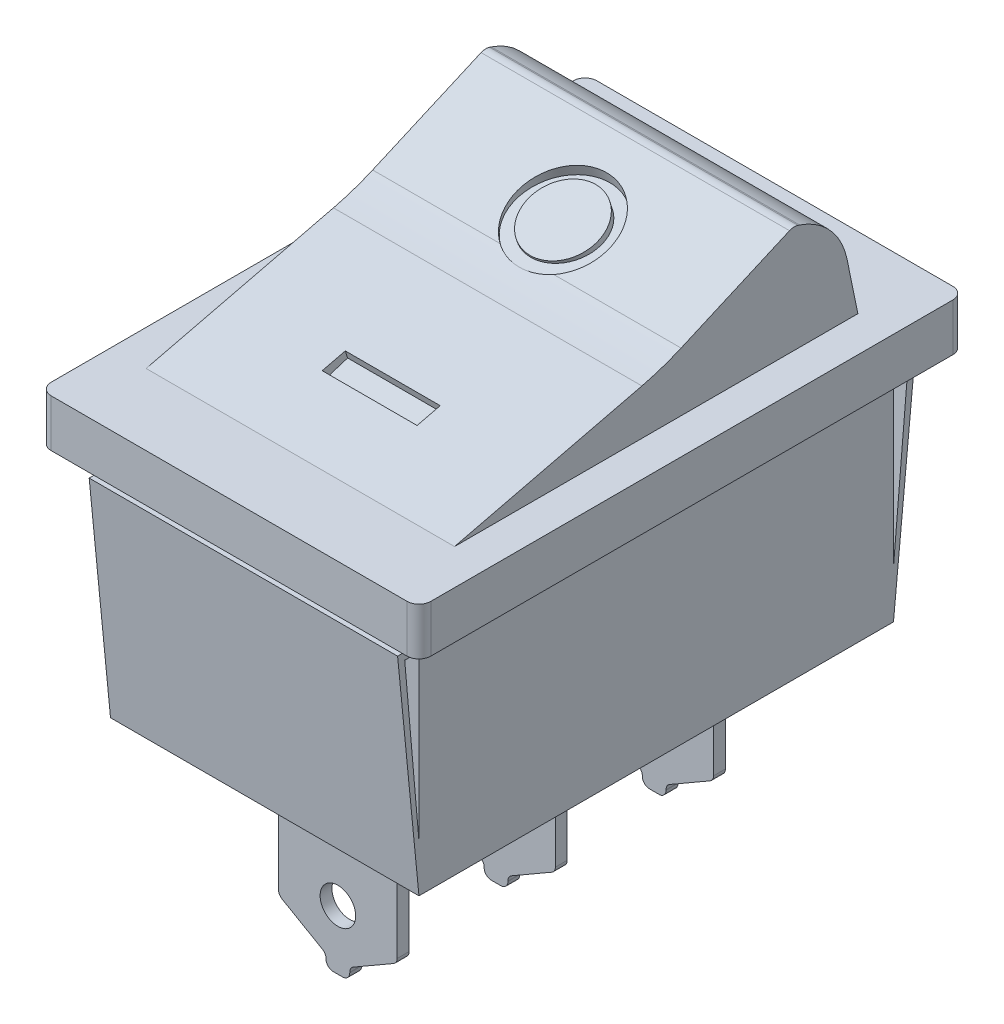
from build123d import *

# Parameters (mm, degrees)
CROQUIS1_W              = 16
CROQUIS1_H              = 23
SALIENTE_EXTRUIR1_DEPTH = 2
CROQUIS2_W              = 13
CROQUIS2_H              = 20
SALIENTE_EXTRUIR2_DEPTH = 10
SALIENTE_EXTRUIR3_DEPTH = 6.5
CROQUIS4_R              = 2
CROQUIS4_R_2            = 1.5
CROQUIS4_W              = 4
CROQUIS4_H              = 1
CORTAR_EXTRUIR1_DEPTH   = 0.6
SALIENTE_EXTRUIR6_DEPTH = 6.5
REDONDEO1_R             = 0.5
CROQUIS6_R              = 0.75
SALIENTE_EXTRUIR7_DEPTH = 0.25
MATRIZL1_COUNT          = 2
MATRIZL1_PITCH          = 6.666666667
MATRIZL2_COUNT          = 2
MATRIZL2_PITCH          = 6.666666667


with BuildPart() as part:
    # Croquis1 → Saliente-Extruir1 (new body)
    with BuildSketch(Plane(origin=(0, 0, 0), x_dir=(1, 0, 0), z_dir=(0, 1, 0))):
        Rectangle(CROQUIS1_W, CROQUIS1_H)
    extrude(amount=SALIENTE_EXTRUIR1_DEPTH)

    # Croquis2 → Saliente-Extruir2 (add)
    with BuildSketch(Plane.XZ):
        Rectangle(CROQUIS2_W, CROQUIS2_H)
    extrude(amount=SALIENTE_EXTRUIR2_DEPTH)

    # Croquis3 → Saliente-Extruir3 (add, symmetric)
    with BuildSketch(Plane(origin=(0, 0, 0), x_dir=(0, 0, -1), z_dir=(1, 0, 0))):
        with BuildLine():
            Line((8.5, 2), (-8.5, 2))
            Line((-8.5, 2), (-0.603629693, 3.914367561))
            ThreePointArc((-0.603629693, 3.914367561), (0.234425411, 4.156697965), (1.048170976, 4.471147542))
            Line((1.048170976, 4.471147542), (5.618369194, 6.470445319))
            ThreePointArc((5.618369194, 6.470445319), (5.795753126, 6.511830798), (5.976190969, 6.486930957))
            Line((5.976190969, 6.486930957), (6.048439126, 6.462964543))
            ThreePointArc((6.048439126, 6.462964543), (7.345603515, 5.609203874), (8.042100494, 4.221243251))
            Line((8.042100494, 4.221243251), (8.5, 2))
        make_face()
    extrude(amount=SALIENTE_EXTRUIR3_DEPTH, both=True)

    # Croquis4 → Cortar-Extruir1 (cut)
    with BuildSketch(Plane(origin=(0, 4.265025315, 1.351360717), x_dir=(1, 0, 0), z_dir=(0, 0.95329272, 0.302047992))):
        with Locations((0, 4)):
            Circle(CROQUIS4_R)
        with Locations((0, 4)):
            Circle(CROQUIS4_R_2, mode=Mode.SUBTRACT)
        with Locations((0, -4)):
            Rectangle(CROQUIS4_W, CROQUIS4_H)
    extrude(amount=-CORTAR_EXTRUIR1_DEPTH, mode=Mode.SUBTRACT)

    # Croquis5 → Saliente-Extruir6 (add, symmetric)
    with BuildSketch(Plane(origin=(0, 0, 0), x_dir=(0, 0, -1), z_dir=(1, 0, 0))):
        Polygon((-10, -0.2), (-10.3, -0.2), (-10.3, -0.5), (-10.6, -0.5), (-10.6, -0.8), (-10.9, -0.8), (-10, -10), (-10, -8), (-10.6, -1.1), (-10.3, -1.1), (-10.3, -0.8), (-10, -0.8), align=None)
    saliente_extruir6 = extrude(amount=SALIENTE_EXTRUIR6_DEPTH, both=True)

    # Simetría2: Saliente-Extruir6 across plane
    add(saliente_extruir6.mirror(Plane.XY))

    # Redondeo1
    redondeo1_edges = [part.edges().sort_by_distance(p)[0] for p in [
        (-8, 1, -11.5),
        (8, 1, -11.5),
        (8, 1, 11.5),
        (-8, 1, 11.5),
    ]]
    fillet(redondeo1_edges, radius=REDONDEO1_R)

    # Croquis6 → Saliente-Extruir7 (add, symmetric)
    with BuildSketch(Plane.XY):
        with BuildLine():
            Line((2.5, -10), (-2.5, -10))
            Line((-2.5, -10), (-2.5, -15.826794919))
            ThreePointArc((-2.5, -15.826794919), (-2.459807621, -15.976794919), (-2.35, -16.08660254))
            Line((-2.35, -16.08660254), (-0.65, -17.068097998))
            ThreePointArc((-0.65, -17.068097998), (-0.540192379, -17.177905619), (-0.5, -17.327905619))
            Line((-0.5, -17.327905619), (-0.5, -17.354700538))
            ThreePointArc((-0.5, -17.354700538), (-0.412132034, -17.566832573), (-0.2, -17.654700538))
            Line((-0.2, -17.654700538), (0.2, -17.654700538))
            ThreePointArc((0.2, -17.654700538), (0.412132034, -17.566832573), (0.5, -17.354700538))
            Line((0.5, -17.354700538), (0.5, -17.327905619))
            ThreePointArc((0.5, -17.327905619), (0.540192379, -17.177905619), (0.65, -17.068097998))
            Line((0.65, -17.068097998), (2.35, -16.08660254))
            ThreePointArc((2.35, -16.08660254), (2.459807621, -15.976794919), (2.5, -15.826794919))
            Line((2.5, -15.826794919), (2.5, -10))
        make_face()
        with Locations((0, -15.154700538)):
            Circle(CROQUIS6_R, mode=Mode.SUBTRACT)
    saliente_extruir7 = extrude(amount=SALIENTE_EXTRUIR7_DEPTH, both=True)

    # MatrizL1: Saliente-Extruir7 ×2
    with Locations(*[(0, 0, -i * MATRIZL1_PITCH) for i in range(1, MATRIZL1_COUNT)]):
        add(saliente_extruir7)

    # MatrizL2: Saliente-Extruir7 ×2
    with Locations(*[(0, 0, i * MATRIZL2_PITCH) for i in range(1, MATRIZL2_COUNT)]):
        add(saliente_extruir7)


solid = part.part
